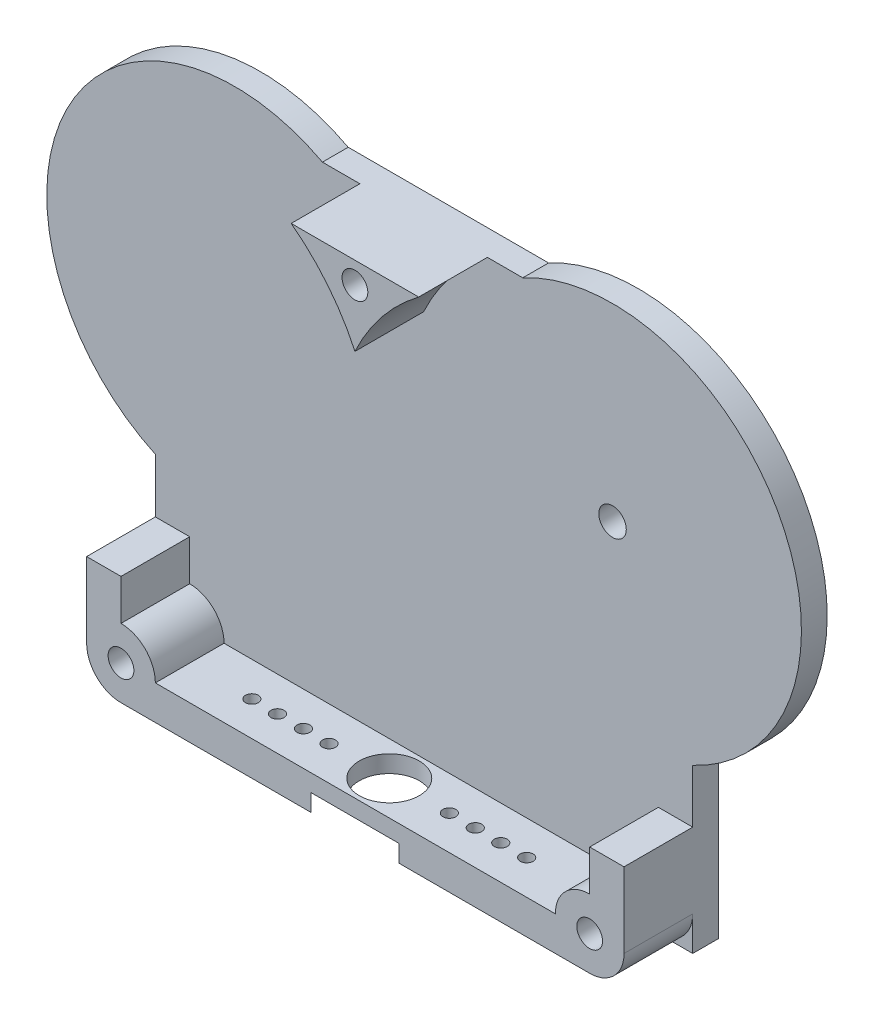
from build123d import *

# Parameters (mm, degrees)
CROQUIS1_R                         = 1.6
BASE_TAPA_DEPTH                    = 3
CROQUIS2_R                         = 1.5
SOPORTES_TAPA_DEPTH                = 8
CROQUIS3_R                         = 3.5
CAJA_HORN_SERVO_EXTERIOR_1_DEPTH   = 4
CROQUIS4_R                         = 0.75
CAJA_HORN_SERVO_EXTERIOR_2_DEPTH   = 2
CROQUIS5_R                         = 0.75
TALADROS_HORN_SERVO_EXTERIOR_DEPTH = 4
CROQUIS6_R                         = 1.5
TALADROS_TAPA_DEPTH                = 11
CROQUIS7_R                         = 1.6
RECTIFICAR_TALADRO_DEPTH           = 3
CHAFL_N_TALADROS_TAPA_SIZE         = 1


with BuildPart() as part:
    # Croquis1 → Base Tapa (new body)
    with BuildSketch(Plane.XY):
        with BuildLine():
            Line((11.548443784, 19.3588474), (-11.785521088, 19.3588474))
            ThreePointArc((-11.785521088, 19.3588474), (-41.605177571, 9.733322379), (-31.246229762, -19.839551086))
            Line((-31.246229762, -19.839551086), (-31.246229762, -38.896936565))
            Line((-31.246229762, -38.896936565), (31.339101257, -38.896936565))
            Line((31.339101257, -38.896936565), (31.339101257, -19.919367151))
            ThreePointArc((31.339101257, -19.919367151), (41.646982557, 9.899296763), (11.548443784, 19.3588474))
        make_face()
        with Locations((-22, 0)):
            Circle(CROQUIS1_R, mode=Mode.SUBTRACT)
        with Locations((22, 0)):
            Circle(CROQUIS1_R, mode=Mode.SUBTRACT)
    extrude(amount=BASE_TAPA_DEPTH)

    # Croquis2 → Soportes tapa (add)
    with BuildSketch(Plane.XY.offset(3)):
        with BuildLine():
            ThreePointArc((-31.246229762, -34.896936565), (-30.074656886, -37.725363689), (-27.246229762, -38.896936565))
            Line((-27.246229762, -38.896936565), (27.339101257, -38.896936565))
            ThreePointArc((27.339101257, -38.896936565), (30.167528382, -37.725363689), (31.339101257, -34.896936565))
            Line((31.339101257, -34.896936565), (31.339101257, -26.154350822))
            Line((31.339101257, -26.154350822), (27.339101257, -26.154350822))
            Line((27.339101257, -26.154350822), (27.339101257, -30.896936565))
            ThreePointArc((27.339101257, -30.896936565), (24.510674133, -32.06850944), (23.339101257, -34.896936565))
            Line((23.339101257, -34.896936565), (-23.246229762, -34.896936565))
            ThreePointArc((-23.246229762, -34.896936565), (-24.417802637, -32.06850944), (-27.246229762, -30.896936565))
            Line((-27.246229762, -30.896936565), (-27.246229762, -26.154350822))
            Line((-27.246229762, -26.154350822), (-31.246229762, -26.154350822))
            Line((-31.246229762, -26.154350822), (-31.246229762, -34.896936565))
        make_face()
        with Locations((-27.246229762, -34.896936565)):
            Circle(CROQUIS2_R, mode=Mode.SUBTRACT)
        with Locations((27.339101257, -34.896936565)):
            Circle(CROQUIS2_R, mode=Mode.SUBTRACT)
        with BuildLine():
            Line((7.423794942, 19.3588474), (-7.423794942, 19.3588474))
            ThreePointArc((-7.423794942, 19.3588474), (-3.142422422, 15.219148939), (0, 10.160252288))
            ThreePointArc((0, 10.160252288), (3.142422422, 15.219148939), (7.423794942, 19.3588474))
        make_face()
        with Locations((0, 16.857587951)):
            Circle(CROQUIS2_R, mode=Mode.SUBTRACT)
    extrude(amount=SOPORTES_TAPA_DEPTH)

    # Croquis3 → Caja Horn servo exterior 1 (cut)
    with BuildSketch(Plane(origin=(0, -34.896936565, 0), x_dir=(1, 0, 0), z_dir=(0, 1, 0))):
        with Locations((0, -7)):
            Circle(CROQUIS3_R)
    extrude(amount=-CAJA_HORN_SERVO_EXTERIOR_1_DEPTH, mode=Mode.SUBTRACT)

    # Croquis4 → Caja Horn servo exterior 2 (cut)
    with BuildSketch(Plane.XZ.offset(38.896936565)):
        with BuildLine():
            Line((-16, 9.5), (-5.123475383, 11))
            ThreePointArc((-5.123475383, 11), (0, 13.5), (5.123475383, 11))
            Line((5.123475383, 11), (16, 9.5))
            ThreePointArc((16, 9.5), (18.5, 7), (16, 4.5))
            Line((16, 4.5), (5.123475383, 3))
            ThreePointArc((5.123475383, 3), (0, 0.5), (-5.123475383, 3))
            Line((-5.123475383, 3), (-16, 4.5))
            ThreePointArc((-16, 4.5), (-18.5, 7), (-16, 9.5))
        make_face()
        with Locations((-16, 7)):
            Circle(CROQUIS4_R, mode=Mode.SUBTRACT)
        with Locations((-13, 7.017965487)):
            Circle(CROQUIS4_R, mode=Mode.SUBTRACT)
        with Locations((-10.006253635, 6.991538598)):
            Circle(CROQUIS4_R, mode=Mode.SUBTRACT)
        with Locations((-7.006253635, 7.009504085)):
            Circle(CROQUIS4_R, mode=Mode.SUBTRACT)
        with Locations((7.006253635, 7.009504085)):
            Circle(CROQUIS4_R, mode=Mode.SUBTRACT)
        with Locations((10.006253635, 6.991538598)):
            Circle(CROQUIS4_R, mode=Mode.SUBTRACT)
        with Locations((13, 7.017965487)):
            Circle(CROQUIS4_R, mode=Mode.SUBTRACT)
        with Locations((16, 7)):
            Circle(CROQUIS4_R, mode=Mode.SUBTRACT)
    extrude(amount=-CAJA_HORN_SERVO_EXTERIOR_2_DEPTH, mode=Mode.SUBTRACT)

    # Croquis5 → Taladros Horn servo exterior (cut)
    with BuildSketch(Plane.XZ.offset(38.896936565)):
        with Locations((-16, 7)):
            Circle(CROQUIS5_R)
        with Locations((-13, 7.017965487)):
            Circle(CROQUIS5_R)
        with Locations((-10.006253635, 6.991538598)):
            Circle(CROQUIS5_R)
        with Locations((-7.006253635, 7.009504085)):
            Circle(CROQUIS5_R)
        with Locations((7.006253635, 7.009504085)):
            Circle(CROQUIS5_R)
        with Locations((10.006253635, 6.991538598)):
            Circle(CROQUIS5_R)
        with Locations((13, 7.017965487)):
            Circle(CROQUIS5_R)
        with Locations((16, 7)):
            Circle(CROQUIS5_R)
    extrude(amount=-TALADROS_HORN_SERVO_EXTERIOR_DEPTH, mode=Mode.SUBTRACT)

    # Croquis6 → Taladros Tapa (cut)
    with BuildSketch(Plane.XY.offset(11)):
        with Locations((0, 16.857587951)):
            Circle(CROQUIS6_R)
        with Locations((27.339101257, -34.896936565)):
            Circle(CROQUIS6_R)
        with Locations((-27.246229762, -34.896936565)):
            Circle(CROQUIS6_R)
    extrude(amount=-TALADROS_TAPA_DEPTH, mode=Mode.SUBTRACT)

    # Croquis7 → Rectificar taladro (add)
    with BuildSketch(Plane.XY.offset(3)):
        with Locations((-22, 0)):
            Circle(CROQUIS7_R)
    extrude(amount=-RECTIFICAR_TALADRO_DEPTH)

    # Chaflán taladros tapa
    chafl_n_taladros_tapa_edges = [part.edges().sort_by_distance(p)[0] for p in [
        (-1.5, 16.857587951, 0),
        (25.839101257, -34.896936565, 0),
        (-28.746229762, -34.896936565, 0),
    ]]
    chamfer(chafl_n_taladros_tapa_edges, length=CHAFL_N_TALADROS_TAPA_SIZE)


solid = part.part
